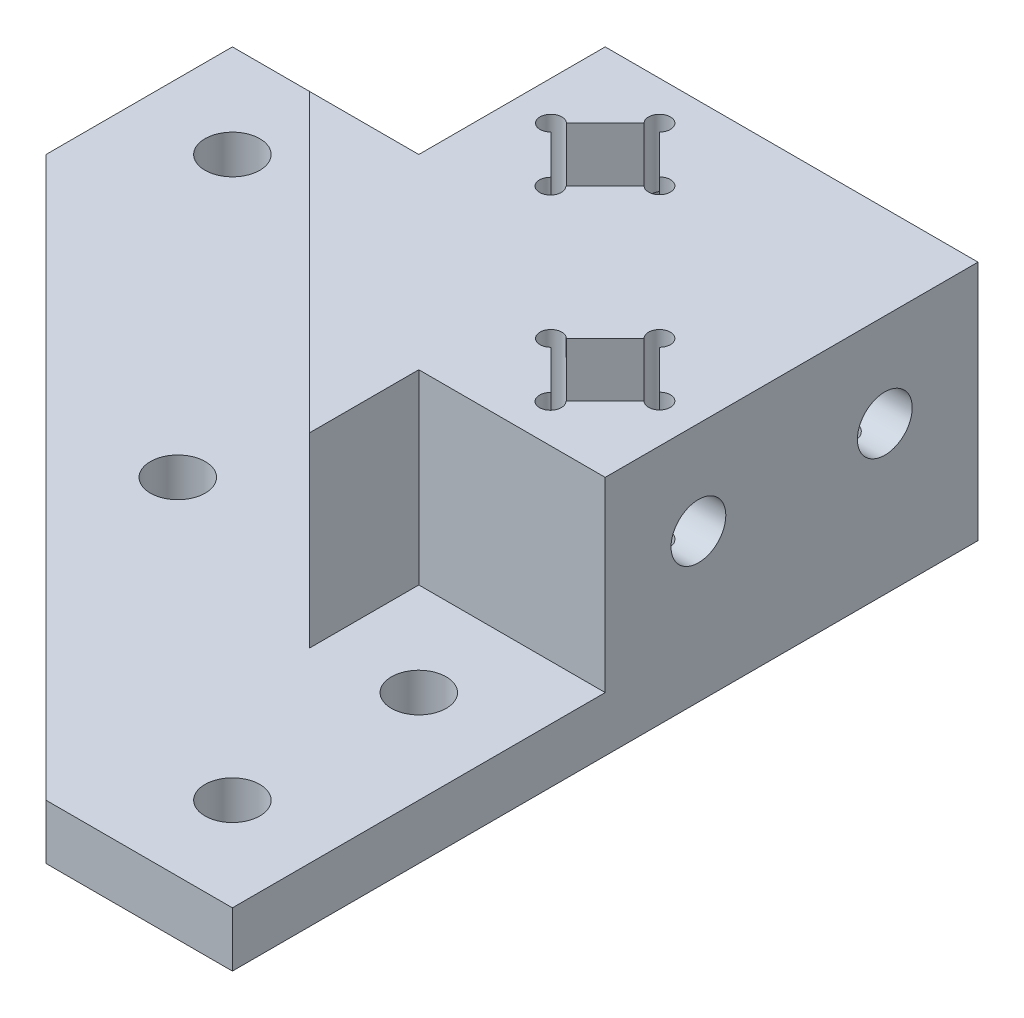
from build123d import *

# Parameters (mm, degrees)
SKETCH1_R                = 2.5
BOSS_EXTRUDE4_DEPTH      = 5
BOSS_EXTRUDE5_DEPTH      = 17
BOSS_EXTRUDE5_DEPTH_BACK = 5
BOSS_EXTRUDE6_DEPTH      = 17
BOSS_EXTRUDE6_DEPTH_BACK = 5
SKETCH3_R                = 0.5
CUT_EXTRUDE4_DEPTH       = 17
SKETCH6_R                = 0.995072339
CUT_EXTRUDE5_DEPTH       = 25
SKETCH10_W               = 12.090214455
SKETCH10_H               = 12.735025893
SKETCH10_W_2             = 13.963890252
SKETCH10_H_2             = 14.708631066
BOSS_EXTRUDE8_DEPTH      = 5
SKETCH11_W               = 13.591519846
SKETCH11_H               = 14.150075456
BOSS_EXTRUDE9_DEPTH      = 5
SKETCH15_R               = 2.5
CUT_EXTRUDE7_DEPTH       = 7
SKETCH14_R               = 2.5
CUT_EXTRUDE8_DEPTH       = 7


with BuildPart() as part:
    # Sketch1 → Boss-Extrude4 (new body)
    with BuildSketch(Plane(origin=(0, 0, 0), x_dir=(1, 0, 0), z_dir=(0, 1, 0))):
        Polygon((-68.817127072, 2.747237569), (-0.817127072, 2.747237569), (-0.817127072, -65.252762431), (-17.817127072, -65.252762431), (-68.817127072, -14.252762431), align=None)
        with Locations((-9.317127072, -5.752762431)):
            Circle(SKETCH1_R, mode=Mode.SUBTRACT)
        with Locations((-26.317127072, -5.752762431)):
            Circle(SKETCH1_R, mode=Mode.SUBTRACT)
        with Locations((-43.317127072, -5.752762431)):
            Circle(SKETCH1_R, mode=Mode.SUBTRACT)
        with Locations((-60.317127072, -5.752762431)):
            Circle(SKETCH1_R, mode=Mode.SUBTRACT)
        with Locations((-9.317127072, -22.752762431)):
            Circle(SKETCH1_R, mode=Mode.SUBTRACT)
        with Locations((-9.317127072, -39.752762431)):
            Circle(SKETCH1_R, mode=Mode.SUBTRACT)
        with Locations((-9.317127072, -56.752762431)):
            Circle(SKETCH1_R, mode=Mode.SUBTRACT)
        with Locations((-37.306719432, -33.742354791)):
            Circle(SKETCH1_R, mode=Mode.SUBTRACT)
        Polygon((-17.817127072, -14.252762431), (-44.775496511, -14.252762431), (-17.817127072, -41.211131871), align=None, mode=Mode.SUBTRACT)
    extrude(amount=BOSS_EXTRUDE4_DEPTH)

    # Sketch2 → Boss-Extrude5 (add, two sides)
    with BuildSketch(Plane(origin=(0, 5, 0), x_dir=(1, 0, 0), z_dir=(0, 1, 0))) as boss_extrude5_sk:
        Polygon((-17.817127072, -14.252762431), (-44.775496511, -14.252762431), (-17.817127072, -41.211131871), align=None)
    extrude(amount=BOSS_EXTRUDE5_DEPTH)
    extrude(boss_extrude5_sk.sketch, amount=-BOSS_EXTRUDE5_DEPTH_BACK)

    # Sketch4 → Boss-Extrude6 (add, two sides)
    with BuildSketch(Plane(origin=(0, 5, 0), x_dir=(1, 0, 0), z_dir=(0, 1, 0))) as boss_extrude6_sk:
        Polygon((-0.817127072, -31.252762431), (-0.817127072, 2.747237569), (-34.817127072, 2.747237569), (-34.817127072, -14.252762431), (-17.817127072, -14.252762431), (-17.817127072, -31.252762431), align=None)
    extrude(amount=BOSS_EXTRUDE6_DEPTH)
    extrude(boss_extrude6_sk.sketch, amount=-BOSS_EXTRUDE6_DEPTH_BACK)

    # Sketch3 → Cut-Extrude4 (cut)
    with BuildSketch(Plane(origin=(-29.514129471, 0, 29.514129471), x_dir=(0.707106781, 0, 0.707106781), z_dir=(-0.707106781, 0, 0.707106781))):
        with Locations((-2.520386408, 18.449747468)):
            Circle(SKETCH3_R)
        with Locations((2.42936106, 13.5)):
            Circle(SKETCH3_R)
        with Locations((-2.520386408, 8.550252532)):
            Circle(SKETCH3_R)
        with Locations((-7.463225234, 13.549854817)):
            Circle(SKETCH3_R)
        Polygon((-7.470133876, 13.5), (-2.520386408, 18.449747468), (2.42936106, 13.5), (-2.520386408, 8.550252532), align=None)
    extrude(amount=-CUT_EXTRUDE4_DEPTH, mode=Mode.SUBTRACT)

    # Sketch6 → Cut-Extrude5 (cut)
    with BuildSketch(Plane(origin=(0, 22, 0), x_dir=(1, 0, 0), z_dir=(0, 1, 0))):
        with Locations((-31.26687454, -5.752762431)):
            Circle(SKETCH6_R)
        with Locations((-26.313804451, -10.748453884)):
            Circle(SKETCH6_R)
        with Locations((-21.367379604, -5.752762431)):
            Circle(SKETCH6_R)
        with Locations((-26.317127072, -0.803014963)):
            Circle(SKETCH6_R)
        Polygon((-31.26687454, -5.752762431), (-26.317127072, -10.702509899), (-21.367379604, -5.752762431), (-26.317127072, -0.803014963), align=None)
        with Locations((-14.26687454, -5.752762431)):
            Circle(SKETCH6_R)
        with Locations((-9.313804451, -10.748453884)):
            Circle(SKETCH6_R)
        with Locations((-4.367379604, -5.752762431)):
            Circle(SKETCH6_R)
        with Locations((-9.317127072, -0.803014963)):
            Circle(SKETCH6_R)
        Polygon((-14.26687454, -5.752762431), (-9.317127072, -10.702509899), (-4.367379604, -5.752762431), (-9.317127072, -0.803014963), align=None)
        with Locations((-14.26687454, -22.752762431)):
            Circle(SKETCH6_R)
        with Locations((-9.313804451, -27.748453884)):
            Circle(SKETCH6_R)
        with Locations((-4.367379604, -22.752762431)):
            Circle(SKETCH6_R)
        with Locations((-9.317127072, -17.803014963)):
            Circle(SKETCH6_R)
        Polygon((-14.26687454, -22.752762431), (-9.317127072, -27.702509899), (-4.367379604, -22.752762431), (-9.317127072, -17.803014963), align=None)
    extrude(amount=-CUT_EXTRUDE5_DEPTH, mode=Mode.SUBTRACT)

    # Sketch10 → Boss-Extrude8 (add)
    with BuildSketch(Plane.XZ):
        with Locations((-26.432881039, 5.808957337)):
            Rectangle(SKETCH10_W, SKETCH10_H)
        with Locations((-9.402846812, 23.47953019)):
            Rectangle(SKETCH10_W_2, SKETCH10_H_2)
    extrude(amount=-BOSS_EXTRUDE8_DEPTH)

    # Sketch11 → Boss-Extrude9 (add)
    with BuildSketch(Plane(origin=(0, 22, 0), x_dir=(1, 0, 0), z_dir=(0, 1, 0))):
        with Locations((-8.658105999, -5.978121074)):
            Rectangle(SKETCH11_W, SKETCH11_H)
    extrude(amount=-BOSS_EXTRUDE9_DEPTH)

    # Sketch15 → Cut-Extrude7 (cut)
    with BuildSketch(Plane(origin=(-0.817127072, 0, 0), x_dir=(0, 0, -1), z_dir=(1, 0, 0))):
        with Locations((-5.752762431, 13.5)):
            Circle(SKETCH15_R)
        with Locations((-22.752762431, 13.5)):
            Circle(SKETCH15_R)
    extrude(amount=-CUT_EXTRUDE7_DEPTH, mode=Mode.SUBTRACT)

    # Sketch14 → Cut-Extrude8 (cut)
    with BuildSketch(Plane(origin=(0, 0, -2.747237569), x_dir=(-1, 0, 0), z_dir=(0, 0, -1))):
        with Locations((26.317127072, 13.5)):
            Circle(SKETCH14_R)
        with Locations((9.317127072, 13.5)):
            Circle(SKETCH14_R)
    extrude(amount=-CUT_EXTRUDE8_DEPTH, mode=Mode.SUBTRACT)


solid = part.part
